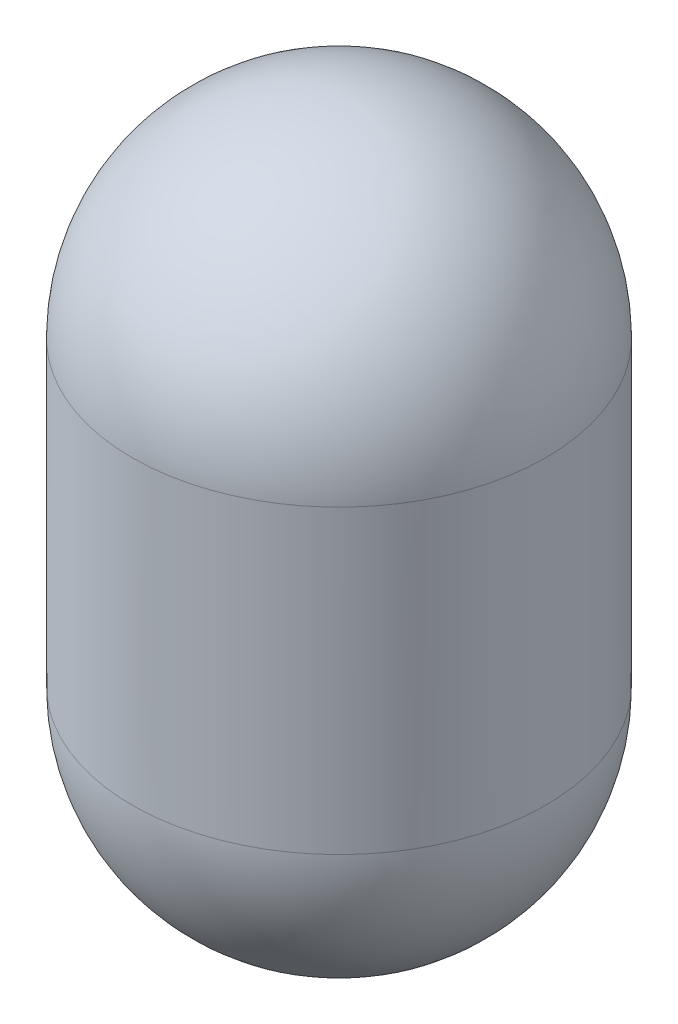
from build123d import *

# Parameters (mm, degrees)
SKETCH2_R      = 69.85
EXTRUDE1_DEPTH = 101.6


with BuildPart() as part:
    # Sketch2 → Extrude1 (new body)
    with BuildSketch(Plane(origin=(0, 0, 0), x_dir=(1, 0, 0), z_dir=(0, 1, 0))):
        Circle(SKETCH2_R)
    extrude(amount=EXTRUDE1_DEPTH)

    # Sketch5 → Revolve1 (revolve)
    with BuildSketch(Plane.XY):
        with BuildLine():
            Line((0, 171.45), (0, 101.6))
            Line((0, 101.6), (-69.85, 101.6))
            ThreePointArc((-69.85, 101.6), (-49.391408666, 150.991408666), (0, 171.45))
        make_face()
    revolve(axis=Axis((0, 101.6, 0), (0, -1, 0)))

    # Sketch6 → Revolve2 (revolve)
    with BuildSketch(Plane.XY):
        with BuildLine():
            Line((0, -69.85), (0, 0))
            Line((0, 0), (-69.85, 0))
            ThreePointArc((-69.85, 0), (-49.391408666, -49.391408666), (0, -69.85))
        make_face()
    revolve(axis=Axis((0, 0, 0), (0, 1, 0)))


solid = part.part
